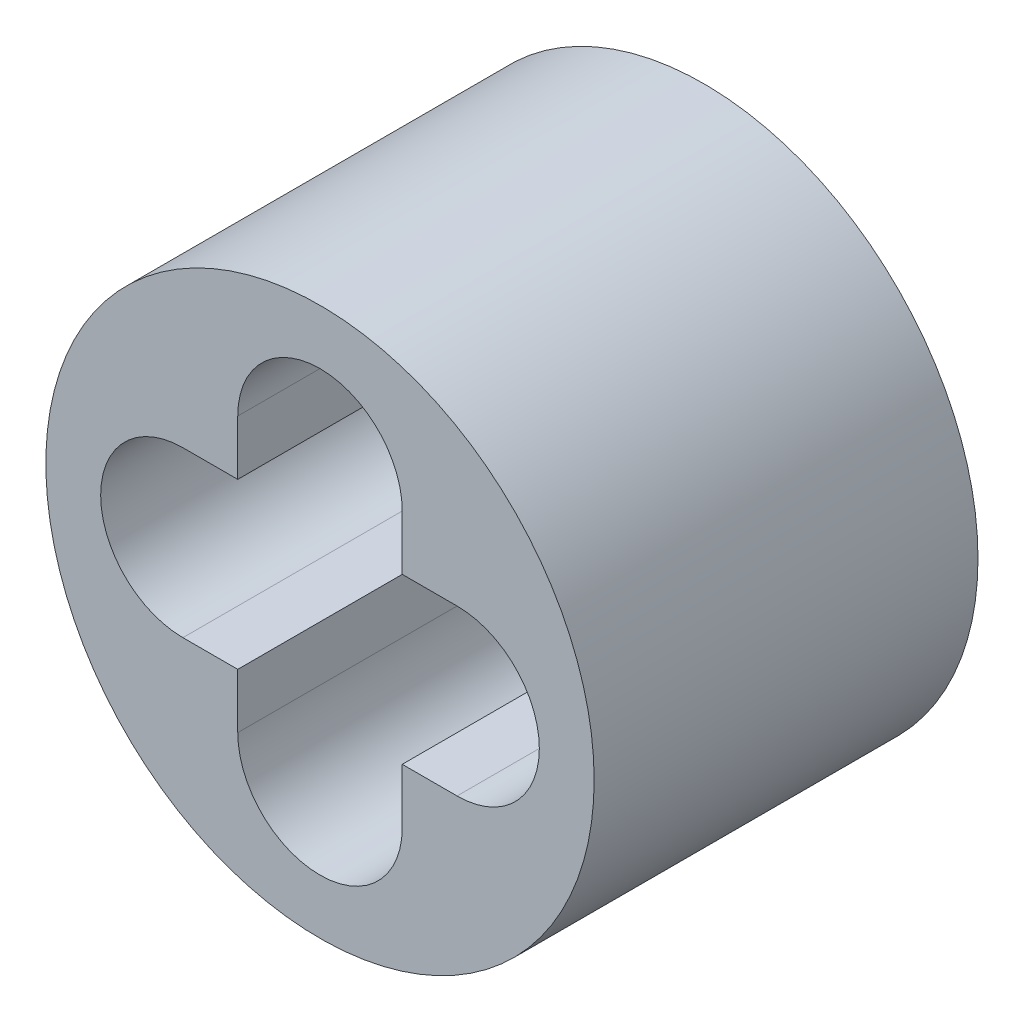
from build123d import *

# Parameters (mm, degrees)
SKETCH1_R           = 5
BOSS_EXTRUDE1_DEPTH = 7


with BuildPart() as part:
    # Sketch1 → Boss-Extrude1 (new body)
    with BuildSketch(Plane.XY):
        Circle(SKETCH1_R)
        with BuildLine():
            Line((-2.5, 1.5), (-1.5, 1.5))
            Line((-1.5, 1.5), (-1.5, 2.5))
            ThreePointArc((-1.5, 2.5), (0, 4), (1.5, 2.5))
            Line((1.5, 2.5), (1.5, 1.5))
            Line((1.5, 1.5), (2.5, 1.5))
            ThreePointArc((2.5, 1.5), (4, 0), (2.5, -1.5))
            Line((2.5, -1.5), (1.5, -1.5))
            Line((1.5, -1.5), (1.5, -2.5))
            ThreePointArc((1.5, -2.5), (0, -4), (-1.5, -2.5))
            Line((-1.5, -2.5), (-1.5, -1.5))
            Line((-1.5, -1.5), (-2.5, -1.5))
            ThreePointArc((-2.5, -1.5), (-4, 0), (-2.5, 1.5))
        make_face(mode=Mode.SUBTRACT)
    extrude(amount=BOSS_EXTRUDE1_DEPTH)


solid = part.part
